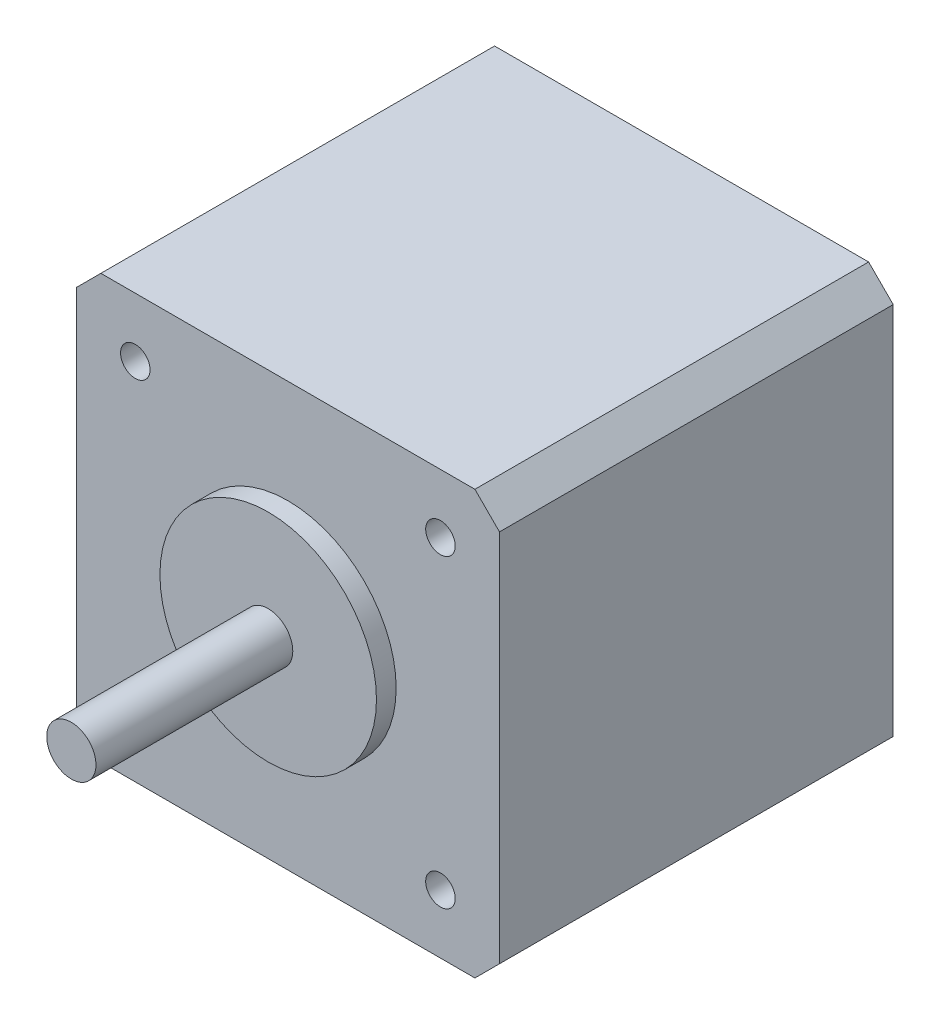
from build123d import *

# Parameters (mm, degrees)
SKETCH1_W           = 43
SKETCH1_H           = 43
BOSS_EXTRUDE1_DEPTH = 40
CHAMFER1_SIZE       = 2.5
SKETCH2_R           = 11
BOSS_EXTRUDE2_DEPTH = 2
SKETCH3_R           = 2.5
BOSS_EXTRUDE3_DEPTH = 20
SKETCH4_R           = 1.5
CUT_EXTRUDE1_DEPTH  = 10


with BuildPart() as part:
    # Sketch1 → Boss-Extrude1 (new body)
    with BuildSketch(Plane.XY):
        Rectangle(SKETCH1_W, SKETCH1_H)
    extrude(amount=BOSS_EXTRUDE1_DEPTH)

    # Chamfer1
    chamfer1_edges = [part.edges().sort_by_distance(p)[0] for p in [
        (21.5, -21.5, 20),
        (-21.5, -21.5, 20),
        (-21.5, 21.5, 20),
        (21.5, 21.5, 20),
    ]]
    chamfer(chamfer1_edges, length=CHAMFER1_SIZE)

    # Sketch2 → Boss-Extrude2 (add)
    with BuildSketch(Plane.XY.offset(40)):
        Circle(SKETCH2_R)
    extrude(amount=BOSS_EXTRUDE2_DEPTH)

    # Sketch3 → Boss-Extrude3 (add)
    with BuildSketch(Plane.XY.offset(42)):
        Circle(SKETCH3_R)
    extrude(amount=BOSS_EXTRUDE3_DEPTH)

    # Sketch4 → Cut-Extrude1 (cut)
    with BuildSketch(Plane.XY.offset(40)):
        with Locations((-15.5, 15.5)):
            Circle(SKETCH4_R)
        with Locations((15.5, 15.5)):
            Circle(SKETCH4_R)
        with Locations((15.5, -15.5)):
            Circle(SKETCH4_R)
        with Locations((-15.5, -15.5)):
            Circle(SKETCH4_R)
    extrude(amount=-CUT_EXTRUDE1_DEPTH, mode=Mode.SUBTRACT)


solid = part.part
